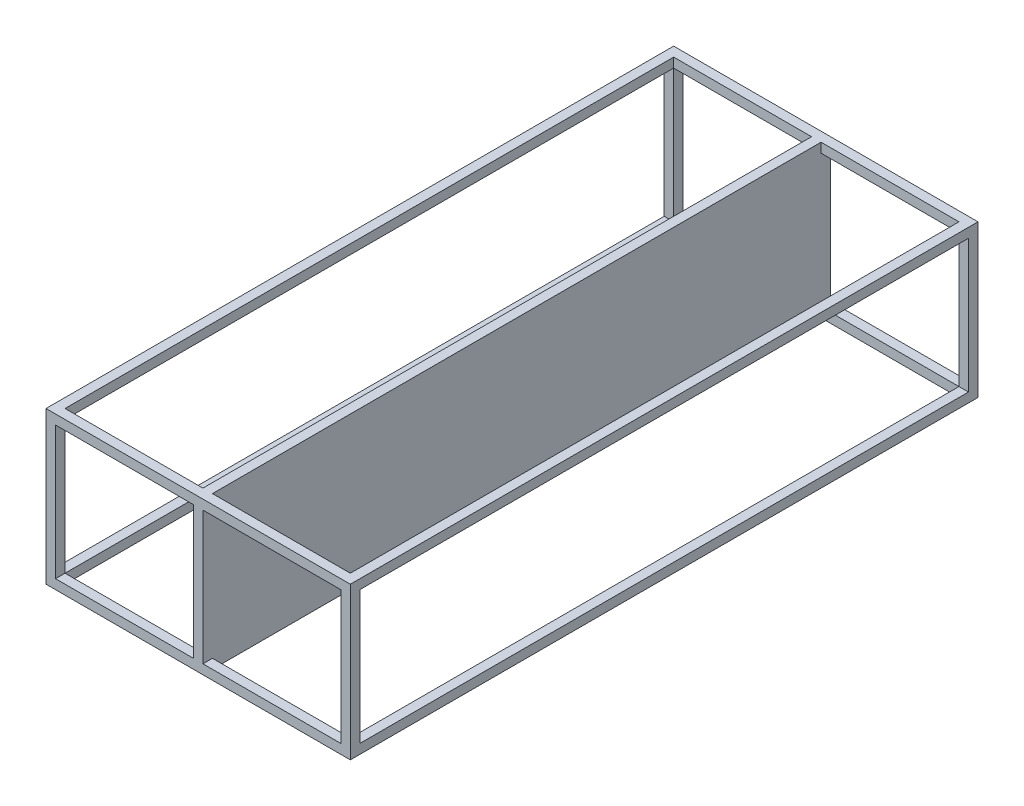
from build123d import *

# Parameters (mm, degrees)
SKETCH3_W           = 160
SKETCH3_H           = 80
SKETCH3_W_2         = 150
SKETCH3_H_2         = 70
BOSS_EXTRUDE2_DEPTH = 5
SKETCH4_W           = 5
SKETCH4_H           = 5
BOSS_EXTRUDE3_DEPTH = 320
BOSS_EXTRUDE4_REACH = 327
SKETCH5_W           = 5
SKETCH5_H           = 80


with BuildPart() as part:
    # Sketch3 → Boss-Extrude2 (new body)
    with BuildSketch(Plane.XY):
        with Locations((80, 40)):
            Rectangle(SKETCH3_W, SKETCH3_H)
        with Locations((80, 40)):
            Rectangle(SKETCH3_W_2, SKETCH3_H_2, mode=Mode.SUBTRACT)
        Polygon((77.5, 75), (77.5, 41.649156988), (77.5, 5), (82.5, 5), (82.5, 41.649156988), (82.5, 75), align=None)
    boss_extrude2 = extrude(amount=BOSS_EXTRUDE2_DEPTH)

    # Sketch4 → Boss-Extrude3 (add)
    with BuildSketch(Plane.XY.offset(5)):
        with Locations((2.5, 2.5)):
            Rectangle(SKETCH4_W, SKETCH4_H)
        with Locations((2.5, 77.5)):
            Rectangle(SKETCH4_W, SKETCH4_H)
        with Locations((157.5, 77.5)):
            Rectangle(SKETCH4_W, SKETCH4_H)
        with Locations((157.5, 2.5)):
            Rectangle(SKETCH4_W, SKETCH4_H)
    extrude(amount=BOSS_EXTRUDE3_DEPTH)

    # Mirror1: Boss-Extrude2 across plane
    add(boss_extrude2.mirror(Plane.XY.offset(165)))

    # Sketch5 → Boss-Extrude4 (add, up to next)
    with BuildSketch(Plane.XY.offset(5), mode=Mode.PRIVATE) as boss_extrude4_sk1:
        with Locations((80, 40)):
            Rectangle(SKETCH5_W, SKETCH5_H)
    boss_extrude4_tool1 = extrude(boss_extrude4_sk1.sketch, amount=BOSS_EXTRUDE4_REACH, mode=Mode.PRIVATE) - part.part
    add(boss_extrude4_tool1.solids().sort_by_distance((80, 40, 5))[0])


solid = part.part
